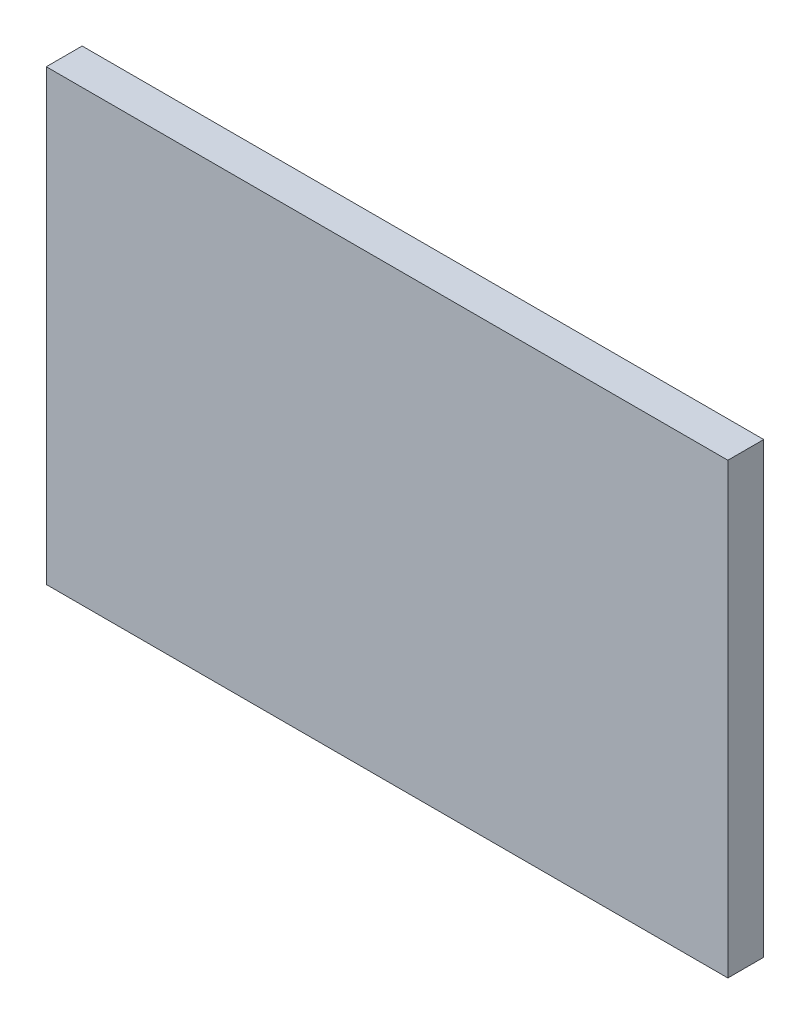
from build123d import *

# Parameters (mm, degrees)
IZIM1_W                     = 380
IZIM1_H                     = 250
Y_KSEKLIK_EKSTR_ZYON1_DEPTH = 20


with BuildPart() as part:
    # Çizim1 → Yükseklik-Ekstrüzyon1 (new body)
    with BuildSketch(Plane.XY):
        with Locations((58.41195593, -49.193548387)):
            Rectangle(IZIM1_W, IZIM1_H)
    extrude(amount=Y_KSEKLIK_EKSTR_ZYON1_DEPTH)


solid = part.part
